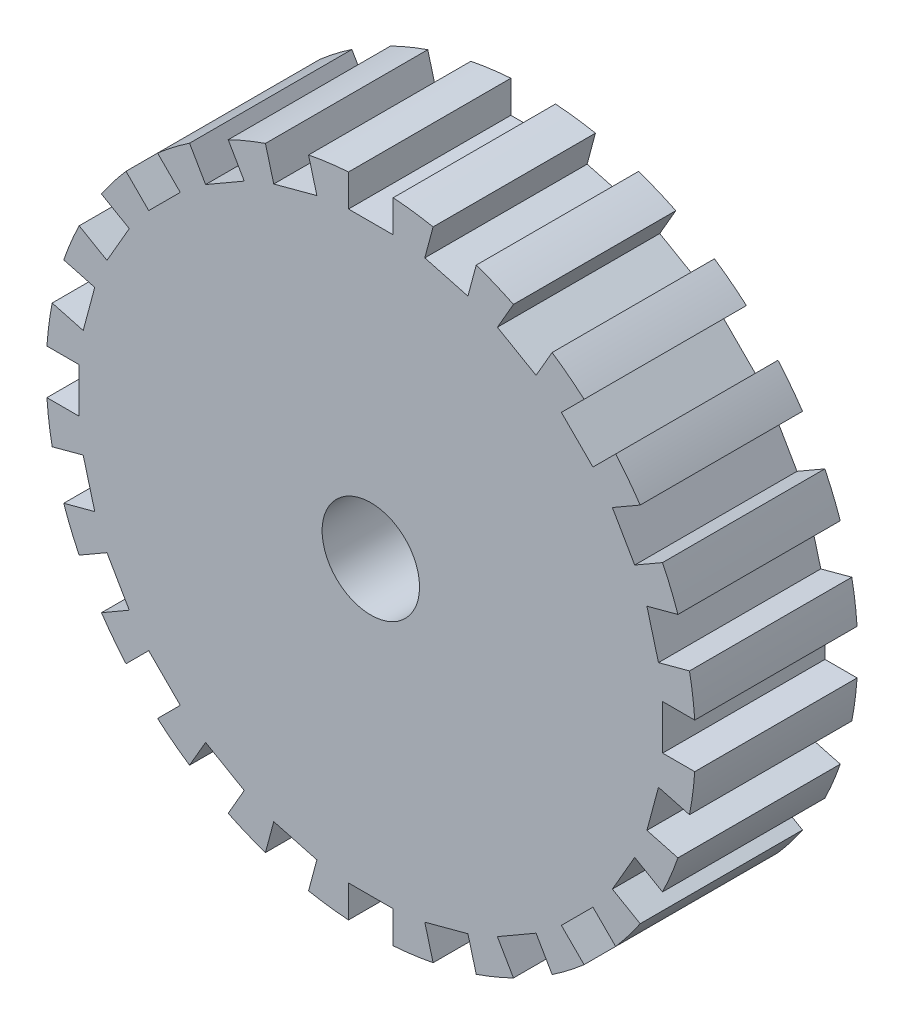
from build123d import *

# Parameters (mm, degrees)
SKETCH2_R           = 40
BOSS_EXTRUDE1_DEPTH = 20
SKETCH3_W           = 5.5
SKETCH3_H           = 4.31
SKETCH3_W_2         = 4.31
SKETCH3_H_2         = 5.5
CUT_EXTRUDE1_DEPTH  = 20
SKETCH4_R           = 6
CUT_EXTRUDE2_DEPTH  = 20


with BuildPart() as part:
    # Sketch2 → Boss-Extrude1 (new body)
    with BuildSketch(Plane.XY):
        Circle(SKETCH2_R)
    extrude(amount=BOSS_EXTRUDE1_DEPTH)

    # Sketch3 → Cut-Extrude1 (cut)
    with BuildSketch(Plane.XY):
        Polygon((-6.648248649, -35.436785829), (-7.763758734, -39.59992614), (-13.076350778, -38.176421392), (-11.960840694, -34.013281081), align=None)
        with Locations((0, -38.105)):
            Rectangle(SKETCH3_W, SKETCH3_H)
        Polygon((-15.59343014, -32.508613266), (-17.74843014, -36.241182756), (-22.51156986, -33.491182756), (-20.35656986, -29.758613266), align=None)
        Polygon((-23.475945135, -27.365032432), (-26.523575362, -30.412662659), (-30.412662659, -26.523575362), (-27.365032432, -23.475945135), align=None)
        Polygon((-29.758613266, -20.35656986), (-33.491182756, -22.51156986), (-36.241182756, -17.74843014), (-32.508613266, -15.59343014), align=None)
        Polygon((-34.013281081, -11.960840694), (-38.176421392, -13.076350778), (-39.59992614, -7.763758734), (-35.436785829, -6.648248649), align=None)
        with Locations((-38.105, 0)):
            Rectangle(SKETCH3_W_2, SKETCH3_H_2)
        Polygon((-35.436785829, 6.648248649), (-39.59992614, 7.763758734), (-38.176421392, 13.076350778), (-34.013281081, 11.960840694), align=None)
        Polygon((-32.508613266, 15.59343014), (-36.241182756, 17.74843014), (-33.491182756, 22.51156986), (-29.758613266, 20.35656986), align=None)
        Polygon((-27.365032432, 23.475945135), (-30.412662659, 26.523575362), (-26.523575362, 30.412662659), (-23.475945135, 27.365032432), align=None)
        Polygon((-20.35656986, 29.758613266), (-22.51156986, 33.491182756), (-17.74843014, 36.241182756), (-15.59343014, 32.508613266), align=None)
        Polygon((-11.960840694, 34.013281081), (-13.076350778, 38.176421392), (-7.763758734, 39.59992614), (-6.648248649, 35.436785829), align=None)
        with Locations((0, 38.105)):
            Rectangle(SKETCH3_W, SKETCH3_H)
        Polygon((6.648248649, 35.436785829), (7.763758734, 39.59992614), (13.076350778, 38.176421392), (11.960840694, 34.013281081), align=None)
        Polygon((15.59343014, 32.508613266), (17.74843014, 36.241182756), (22.51156986, 33.491182756), (20.35656986, 29.758613266), align=None)
        Polygon((23.475945135, 27.365032432), (26.523575362, 30.412662659), (30.412662659, 26.523575362), (27.365032432, 23.475945135), align=None)
        Polygon((29.758613266, 20.35656986), (33.491182756, 22.51156986), (36.241182756, 17.74843014), (32.508613266, 15.59343014), align=None)
        Polygon((34.013281081, 11.960840694), (38.176421392, 13.076350778), (39.59992614, 7.763758734), (35.436785829, 6.648248649), align=None)
        with Locations((38.105, 0)):
            Rectangle(SKETCH3_W_2, SKETCH3_H_2)
        Polygon((35.436785829, -6.648248649), (39.59992614, -7.763758734), (38.176421392, -13.076350778), (34.013281081, -11.960840694), align=None)
        Polygon((32.508613266, -15.59343014), (36.241182756, -17.74843014), (33.491182756, -22.51156986), (29.758613266, -20.35656986), align=None)
        Polygon((27.365032432, -23.475945135), (30.412662659, -26.523575362), (26.523575362, -30.412662659), (23.475945135, -27.365032432), align=None)
        Polygon((20.35656986, -29.758613266), (22.51156986, -33.491182756), (17.74843014, -36.241182756), (15.59343014, -32.508613266), align=None)
        Polygon((11.960840694, -34.013281081), (13.076350778, -38.176421392), (7.763758734, -39.59992614), (6.648248649, -35.436785829), align=None)
    extrude(amount=CUT_EXTRUDE1_DEPTH, mode=Mode.SUBTRACT)

    # Sketch4 → Cut-Extrude2 (cut)
    with BuildSketch(Plane.XY):
        Circle(SKETCH4_R)
    extrude(amount=CUT_EXTRUDE2_DEPTH, mode=Mode.SUBTRACT)


solid = part.part
